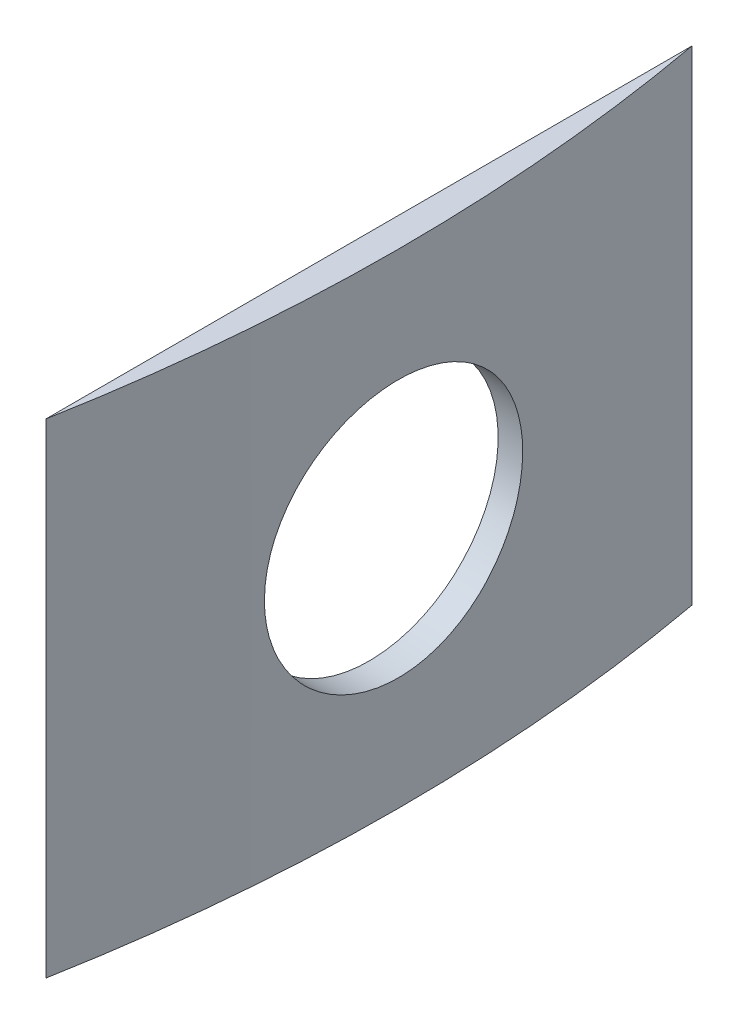
from build123d import *

# Parameters (mm, degrees)
BOSS_EXTRUDE1_DEPTH = 15
CUT_EXTRUDE1_DEPTH  = 40


with BuildPart() as part:
    # Sketch2 → Boss-Extrude1 (new body)
    with BuildSketch(Plane(origin=(0, 0, 0), x_dir=(1, 0, 0), z_dir=(0, 1, 0))):
        with BuildLine():
            Line((54.845806585, -8.617162068), (54.845806585, -10))
            ThreePointArc((54.845806585, -10), (55.523491502, -5.020397537), (55.75, 0))
            Line((55.75, 0), (55.518627344, 0))
            ThreePointArc((55.518627344, 0), (55.350166573, -4.321694398), (54.845806585, -8.617162068))
        make_face()
        with BuildLine():
            ThreePointArc((55.75, 0), (55.523491502, 5.020397537), (54.845806585, 10))
            Line((54.845806585, 10), (54.845806585, 8.617162068))
            ThreePointArc((54.845806585, 8.617162068), (55.350166573, 4.321694398), (55.518627344, 0))
            Line((55.518627344, 0), (55.75, 0))
        make_face()
        with BuildLine():
            Line((54.845806585, 8.617162068), (54.845806585, 0))
            Line((54.845806585, 0), (55.518627344, 0))
            ThreePointArc((55.518627344, 0), (55.350166573, 4.321694398), (54.845806585, 8.617162068))
        make_face()
        with BuildLine():
            Line((55.518627344, 0), (54.845806585, 0))
            Line((54.845806585, 0), (54.845806585, -8.617162068))
            ThreePointArc((54.845806585, -8.617162068), (55.350166573, -4.321694398), (55.518627344, 0))
        make_face()
    extrude(amount=BOSS_EXTRUDE1_DEPTH)

    # Sketch3 → Cut-Extrude1 (cut)
    with BuildSketch(Plane.ZY.offset(-43.464559905)):
        with BuildLine():
            ThreePointArc((0, 11.5), (-4, 7.5), (0, 3.5))
            Line((0, 3.5), (0, 7.5))
            Line((0, 7.5), (0, 11.5))
        make_face()
        with BuildLine():
            Line((0, 7.5), (0, 3.5))
            ThreePointArc((0, 3.5), (2.828427125, 4.671572875), (4, 7.5))
            Line((4, 7.5), (0, 7.5))
        make_face()
        with BuildLine():
            Line((0, 11.5), (0, 7.5))
            Line((0, 7.5), (4, 7.5))
            ThreePointArc((4, 7.5), (2.828427125, 10.328427125), (0, 11.5))
        make_face()
    extrude(amount=-CUT_EXTRUDE1_DEPTH, mode=Mode.SUBTRACT)


solid = part.part
